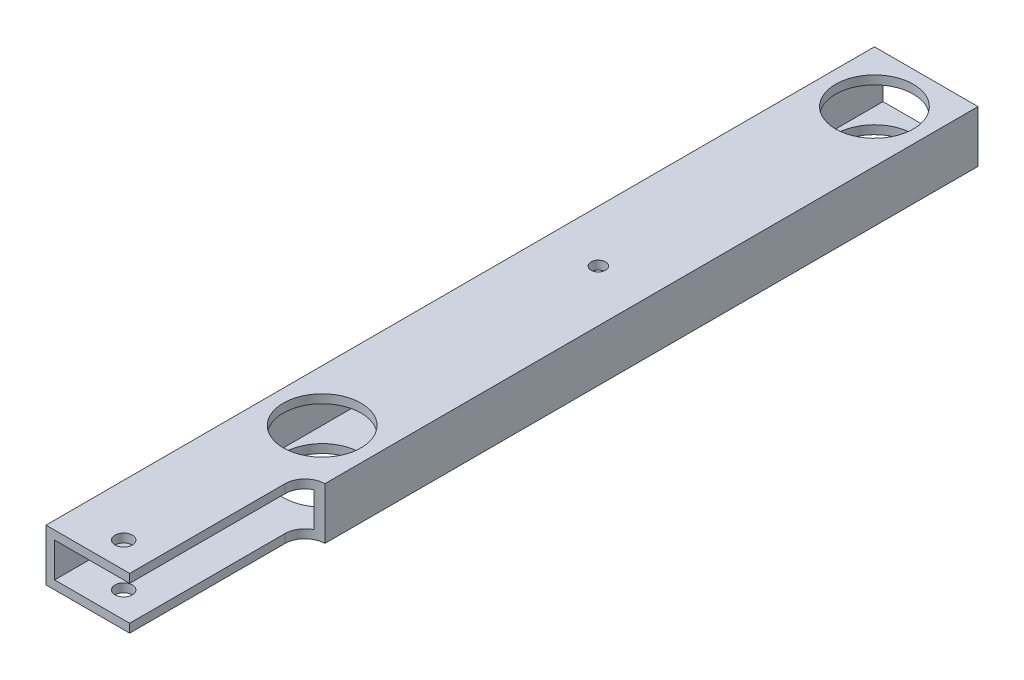
from build123d import *

# Parameters (mm, degrees)
SKETCH1_W           = 38.1
SKETCH1_H           = 19.05
SKETCH1_W_2         = 31.75
SKETCH1_H_2         = 12.7
BOSS_EXTRUDE1_DEPTH = 304.8
SKETCH2_R           = 14.2875
CUT_EXTRUDE1_DEPTH  = 20.05
SKETCH3_R           = 3.175
CUT_EXTRUDE2_DEPTH  = 20.05
CUT_EXTRUDE3_DEPTH  = 20.05
SKETCH5_R           = 2.667
CUT_EXTRUDE4_DEPTH  = 20.05
CUT_EXTRUDE5_REACH  = 21.05
SKETCH6_R           = 6.35


with BuildPart() as part:
    # Sketch1 → Boss-Extrude1 (new body)
    with BuildSketch(Plane.XY):
        with Locations((19.05, 9.525)):
            Rectangle(SKETCH1_W, SKETCH1_H)
        with Locations((19.05, 9.525)):
            Rectangle(SKETCH1_W_2, SKETCH1_H_2, mode=Mode.SUBTRACT)
    extrude(amount=BOSS_EXTRUDE1_DEPTH)

    # Sketch2 → Cut-Extrude1 (cut, through all)
    with BuildSketch(Plane(origin=(0, 19.05, 0), x_dir=(1, 0, 0), z_dir=(0, 1, 0))):
        with Locations((19.05, -19.05)):
            Circle(SKETCH2_R)
        with Locations((19.05, -222.25)):
            Circle(SKETCH2_R)
    extrude(amount=-CUT_EXTRUDE1_DEPTH, mode=Mode.SUBTRACT)

    # Sketch3 → Cut-Extrude2 (cut, through all)
    with BuildSketch(Plane(origin=(0, 19.05, 0), x_dir=(1, 0, 0), z_dir=(0, 1, 0))):
        with Locations((19.05, -295.275)):
            Circle(SKETCH3_R)
    extrude(amount=-CUT_EXTRUDE2_DEPTH, mode=Mode.SUBTRACT)

    # Sketch4 → Cut-Extrude3 (cut, through all)
    with BuildSketch(Plane(origin=(0, 19.05, 0), x_dir=(1, 0, 0), z_dir=(0, 1, 0))):
        with BuildLine():
            Line((30.774464213, -304.8), (30.774464213, -247.65))
            ThreePointArc((30.774464213, -247.65), (32.920063969, -242.470063969), (38.1, -240.324464213))
            Line((38.1, -240.324464213), (38.1, -304.8))
            Line((38.1, -304.8), (30.774464213, -304.8))
        make_face()
    extrude(amount=-CUT_EXTRUDE3_DEPTH, mode=Mode.SUBTRACT)

    # Sketch5 → Cut-Extrude4 (cut, through all)
    with BuildSketch(Plane(origin=(0, 19.05, 0), x_dir=(1, 0, 0), z_dir=(0, 1, 0))):
        with Locations((19.05, -120.65)):
            Circle(SKETCH5_R)
    extrude(amount=-CUT_EXTRUDE4_DEPTH, mode=Mode.SUBTRACT)

    # Sketch6 → Cut-Extrude5 (cut, up to next)
    with BuildSketch(Plane.XZ, mode=Mode.PRIVATE) as cut_extrude5_sk1:
        with Locations((19.05, 120.65)):
            Circle(SKETCH6_R)
    cut_extrude5_tool1 = extrude(cut_extrude5_sk1.sketch, amount=-CUT_EXTRUDE5_REACH, mode=Mode.PRIVATE) & part.part
    add(cut_extrude5_tool1.solids().sort_by_distance((19.05, 0, 120.65))[0], mode=Mode.SUBTRACT)


solid = part.part
